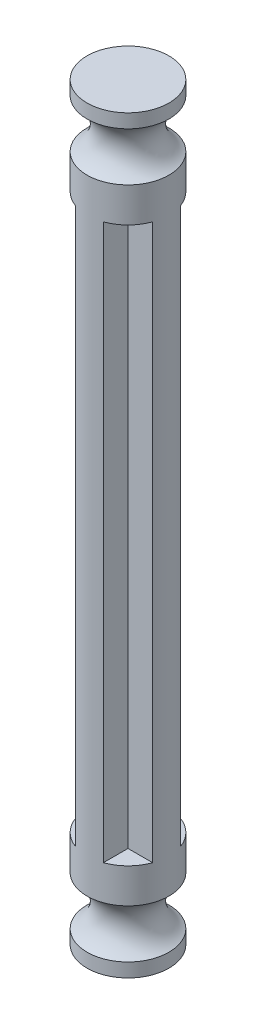
from build123d import *

# Parameters (mm, degrees)
EXTRUDE_2_DEPTH = 40


with BuildPart() as part:
    # 草图1 → 凸台-拉伸2 (new body)
    with BuildSketch(Plane(origin=(0, 0, 0), x_dir=(1, 0, 0), z_dir=(0, 1, 0))):
        with BuildLine():
            Line((1, 1), (1, 2.775338))
            ThreePointArc((1, 2.775338), (0, 2.95), (-1, 2.775338))
            Line((-1, 2.775338), (-1, 1))
            Line((-1, 1), (-2.775338, 1))
            ThreePointArc((-2.775338, 1), (-2.95, 0), (-2.775338, -1))
            Line((-2.775338, -1), (-1, -1))
            Line((-1, -1), (-1, -2.775338))
            ThreePointArc((-1, -2.775338), (0, -2.95), (1, -2.775338))
            Line((1, -2.775338), (1, -1))
            Line((1, -1), (2.775338, -1))
            ThreePointArc((2.775338, -1), (2.95, 0), (2.775338, 1))
            Line((2.775338, 1), (1, 1))
        make_face()
    extrude(amount=EXTRUDE_2_DEPTH)

    # 草图3 → 旋转3 (revolve)
    with BuildSketch(Plane(origin=(0, 0, 0), x_dir=(0, 0, -1), z_dir=(1, 0, 0))):
        with BuildLine():
            Line((0, 40), (0, 47))
            Line((0, 47), (2.95, 47))
            Line((2.95, 47), (2.95, 46))
            ThreePointArc((2.95, 46), (1.918246, 44.25), (2.95, 42.5))
            Line((2.95, 42.5), (2.95, 40))
            Line((2.95, 40), (0, 40))
        make_face()
        with BuildLine():
            Line((0, 0), (0, -7))
            Line((0, -7), (2.95, -7))
            Line((2.95, -7), (2.95, -6))
            ThreePointArc((2.95, -6), (1.918246, -4.25), (2.95, -2.5))
            Line((2.95, -2.5), (2.95, 0))
            Line((2.95, 0), (0, 0))
        make_face()
    revolve(axis=Axis((0, 0, 0), (0, -1, 0)))


solid = part.part
